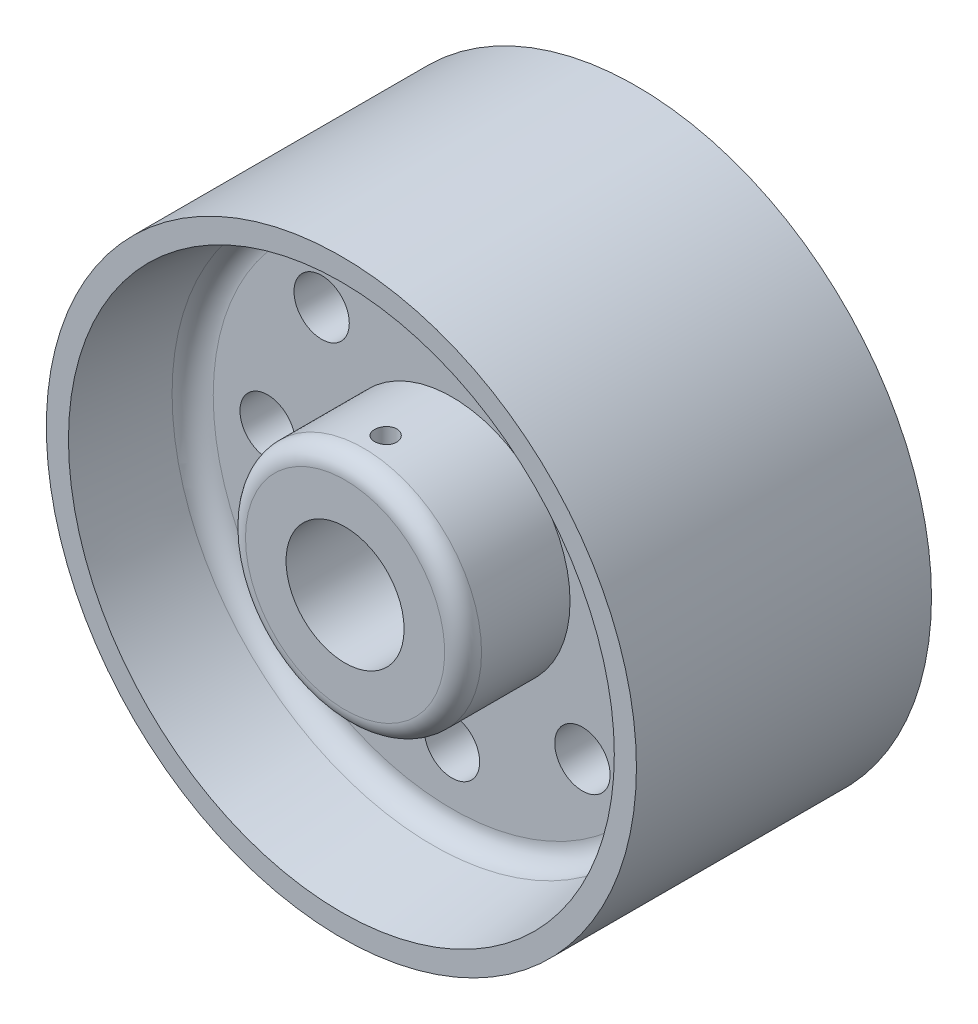
from build123d import *

# Parameters (mm, degrees)
SKETCH2_R            = 3.75
CUT_EXTRUDE1_DEPTH   = 6
CUT_EXTRUDE2_START   = 7.858117
SKETCH3_R            = 1.5
CUT_EXTRUDE2_DEPTH   = 8.141883
FILLET1_R            = 3
FILLET3_R            = 2.5
FILLET1_OF_MIRROR1_R = 3
FILLET3_OF_MIRROR1_R = 2.5


with BuildPart() as part:
    # Sketch1 → Revolve1 (revolve)
    with BuildSketch(Plane(origin=(0, 0, 0), x_dir=(0, 0, -1), z_dir=(1, 0, 0))):
        Polygon((0, 8), (0, 40), (-20, 40), (-20, 37), (-5, 35), (-5, 16), (-19.5, 16), (-19.5, 8), align=None)
    revolve1 = revolve(axis=Axis((0, 0, 30), (0, 0, -1)))

    # Sketch2 → Cut-Extrude1 (cut, through all)
    with BuildSketch(Plane.XY.offset(5)):
        with Locations((0, 25)):
            Circle(SKETCH2_R)
        with Locations((17.67766953, 17.67766953)):
            Circle(SKETCH2_R)
        with Locations((25, 0)):
            Circle(SKETCH2_R)
        with Locations((17.67766953, -17.67766953)):
            Circle(SKETCH2_R)
        with Locations((0, -25)):
            Circle(SKETCH2_R)
        with Locations((-17.67766953, -17.67766953)):
            Circle(SKETCH2_R)
        with Locations((-25, 0)):
            Circle(SKETCH2_R)
        with Locations((-17.67766953, 17.67766953)):
            Circle(SKETCH2_R)
    cut_extrude1 = extrude(amount=-CUT_EXTRUDE1_DEPTH, mode=Mode.SUBTRACT)

    # Sketch3 → Cut-Extrude2 (cut)
    with BuildSketch(Plane(origin=(0, 0, 0), x_dir=(1, 0, 0), z_dir=(0, 1, 0)).offset(CUT_EXTRUDE2_START)):
        with Locations((0, -14)):
            Circle(SKETCH3_R)
    cut_extrude2 = extrude(amount=CUT_EXTRUDE2_DEPTH, mode=Mode.SUBTRACT)

    # Fillet1
    fillet1_edges = [part.edges().sort_by_distance(p)[0] for p in [
        (0, -35, 5),
    ]]
    fillet(fillet1_edges, radius=FILLET1_R)

    # Fillet3
    fillet3_edges = [part.edges().sort_by_distance(p)[0] for p in [
        (0, -16, 19.5),
    ]]
    fillet(fillet3_edges, radius=FILLET3_R)

    # Mirror1: Revolve1, Cut-Extrude1, Cut-Extrude2 across plane
    add(revolve1.mirror(Plane.XY))
    add(cut_extrude1.mirror(Plane.XY), mode=Mode.SUBTRACT)
    add(cut_extrude2.mirror(Plane.XY), mode=Mode.SUBTRACT)

    # Fillet1 of Mirror1
    fillet1_of_mirror1_edges = [part.edges().sort_by_distance(p)[0] for p in [
        (0, -35, -5),
    ]]
    fillet(fillet1_of_mirror1_edges, radius=FILLET1_OF_MIRROR1_R)

    # Fillet3 of Mirror1
    fillet3_of_mirror1_edges = [part.edges().sort_by_distance(p)[0] for p in [
        (0, -16, -19.5),
    ]]
    fillet(fillet3_of_mirror1_edges, radius=FILLET3_OF_MIRROR1_R)


solid = part.part
